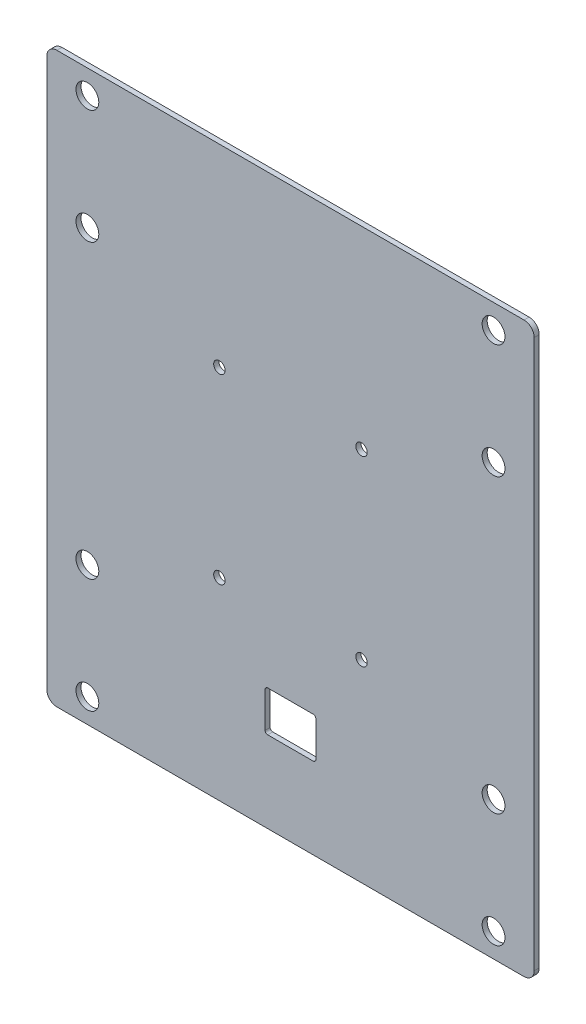
from build123d import *

# Parameters (mm, degrees)
SKETCH1_W                      = 304.8
SKETCH1_H                      = 355.6
BOSS_EXTRUDE1_DEPTH            = 3.175
F_9_16_0_5625_DIAMETER_HOLE1_D = 14.2875
FILLET1_R                      = 6.35
F_1_4_CLEARANCE_HOLE1_D        = 7.14248
SKETCH2_W                      = 31.75
SKETCH2_H                      = 25.4
CUT_EXTRUDE1_DEPTH             = 4.175
FILLET2_R                      = 1.5875


with BuildPart() as part:
    # Sketch1 → Boss-Extrude1 (new body)
    with BuildSketch(Plane.XY):
        Rectangle(SKETCH1_W, SKETCH1_H)
    extrude(amount=BOSS_EXTRUDE1_DEPTH)

    # 9/16 (0.5625) Diameter Hole1 (through all)
    with Locations(Plane.XY.offset(3.175)):
        with Locations((-127, 162.71875), (-127, 91.28125), (-127, -91.28125), (-127, -162.71875), (127, -162.71875), (127, -91.28125), (127, 91.28125), (127, 162.71875)):
            Hole(F_9_16_0_5625_DIAMETER_HOLE1_D / 2)

    # Fillet1
    fillet1_edges = [part.edges().sort_by_distance(p)[0] for p in [
        (152.4, -177.8, 1.5875),
        (-152.4, -177.8, 1.5875),
        (-152.4, 177.8, 1.5875),
        (152.4, 177.8, 1.5875),
    ]]
    fillet(fillet1_edges, radius=FILLET1_R)

    # 1/4 Clearance Hole1 (through all)
    with Locations(Plane(origin=(0, 0, 0), x_dir=(-1, 0, 0), z_dir=(0, 0, -1))):
        with Locations((-44.45, 56.9515625), (-44.45, -56.9515625), (44.45, 56.9515625), (44.45, -56.9515625)):
            Hole(F_1_4_CLEARANCE_HOLE1_D / 2)

    # Sketch2 → Cut-Extrude1 (cut, through all)
    with BuildSketch(Plane.XY.offset(3.175)):
        with Locations((0, -114.3)):
            Rectangle(SKETCH2_W, SKETCH2_H)
    extrude(amount=-CUT_EXTRUDE1_DEPTH, mode=Mode.SUBTRACT)

    # Fillet2
    fillet2_edges = [part.edges().sort_by_distance(p)[0] for p in [
        (-15.875, -101.6, 1.5875),
        (15.875, -101.6, 1.5875),
        (15.875, -127, 1.5875),
        (-15.875, -127, 1.5875),
    ]]
    fillet(fillet2_edges, radius=FILLET2_R)


solid = part.part
